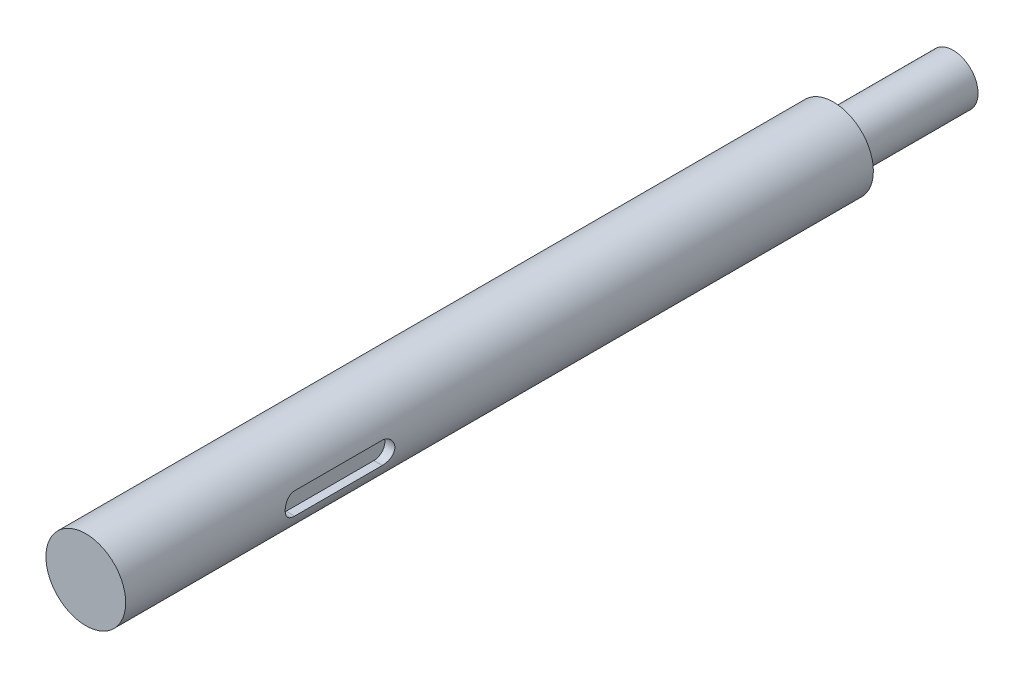
from build123d import *

# Parameters (mm, degrees)
SKETCH_1_R          = 4
EXTRUDE_1_DEPTH     = 75
SKETCH_2_R          = 2.5
EXTRUDE_2_DEPTH     = 12
CUT_EXTRUDE_1_DEPTH = 2


with BuildPart() as part:
    # ｽｹｯﾁ1 → ﾎﾞｽ - 押し出し1 (new body)
    with BuildSketch(Plane.XY):
        Circle(SKETCH_1_R)
    extrude(amount=EXTRUDE_1_DEPTH)

    # ｽｹｯﾁ2 → ﾎﾞｽ - 押し出し2 (add)
    with BuildSketch(Plane(origin=(0, 0, 0), x_dir=(-1, 0, 0), z_dir=(0, 0, -1))):
        Circle(SKETCH_2_R)
    extrude(amount=EXTRUDE_2_DEPTH)

    # ｽｹｯﾁ3 → ｶｯﾄ - 押し出し1 (cut, through all)
    with BuildSketch(Plane(origin=(3, 0, 0), x_dir=(0, 0, -1), z_dir=(1, 0, 0))):
        with BuildLine():
            Line((-57.9, 1.1), (-49.1, 1.1))
            ThreePointArc((-49.1, 1.1), (-48, 0), (-49.1, -1.1))
            Line((-49.1, -1.1), (-57.9, -1.1))
            ThreePointArc((-57.9, -1.1), (-59, 0), (-57.9, 1.1))
        make_face()
    extrude(amount=CUT_EXTRUDE_1_DEPTH, mode=Mode.SUBTRACT)


solid = part.part
